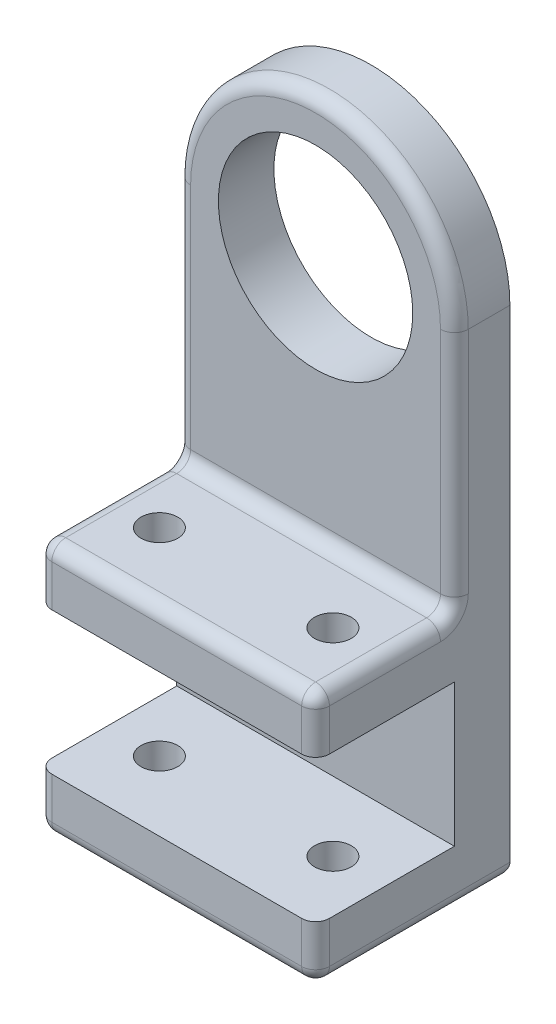
from build123d import *

# Parameters (mm, degrees)
SKETCH1_R           = 14
BOSS_EXTRUDE1_DEPTH = 8
SKETCH2_W           = 40
SKETCH2_H           = 8
BOSS_EXTRUDE2_DEPTH = 20
SKETCH3_R           = 2.65
CUT_EXTRUDE1_DEPTH  = 37.5
FILLET1_R           = 2


with BuildPart() as part:
    # Sketch1 → Boss-Extrude1 (new body)
    with BuildSketch(Plane.XY):
        with BuildLine():
            Line((-20, 0), (-20, -71.5))
            Line((-20, -71.5), (20, -71.5))
            Line((20, -71.5), (20, 0))
            ThreePointArc((20, 0), (0, 20), (-20, 0))
        make_face()
        Circle(SKETCH1_R, mode=Mode.SUBTRACT)
    extrude(amount=BOSS_EXTRUDE1_DEPTH)

    # Sketch2 → Boss-Extrude2 (add)
    with BuildSketch(Plane.XY.offset(8)):
        with Locations((0, -39)):
            Rectangle(SKETCH2_W, SKETCH2_H)
        with Locations((0, -67.5)):
            Rectangle(SKETCH2_W, SKETCH2_H)
    extrude(amount=BOSS_EXTRUDE2_DEPTH)

    # Sketch3 → Cut-Extrude1 (cut, through all)
    with BuildSketch(Plane(origin=(0, -35, 0), x_dir=(1, 0, 0), z_dir=(0, 1, 0))):
        with Locations((-12.5, -18)):
            Circle(SKETCH3_R)
        with Locations((12.5, -18)):
            Circle(SKETCH3_R)
    extrude(amount=-CUT_EXTRUDE1_DEPTH, mode=Mode.SUBTRACT)

    # Fillet1
    fillet1_edges = [part.edges().sort_by_distance(p)[0] for p in [
        (20, -17.5, 8),
        (-20, -35, 18),
        (0, -35, 8),
        (20, -35, 18),
        (-20, -39, 28),
        (20, -39, 28),
        (0, -35, 28),
        (20, -67.5, 28),
        (-20, -67.5, 28),
        (0, -71.5, 28),
        (0, 20, 8),
        (0, -71.5, 0),
        (20, -71.5, 14),
        (-20, -71.5, 14),
        (-20, -17.5, 8),
    ]]
    fillet(fillet1_edges, radius=FILLET1_R)


solid = part.part
